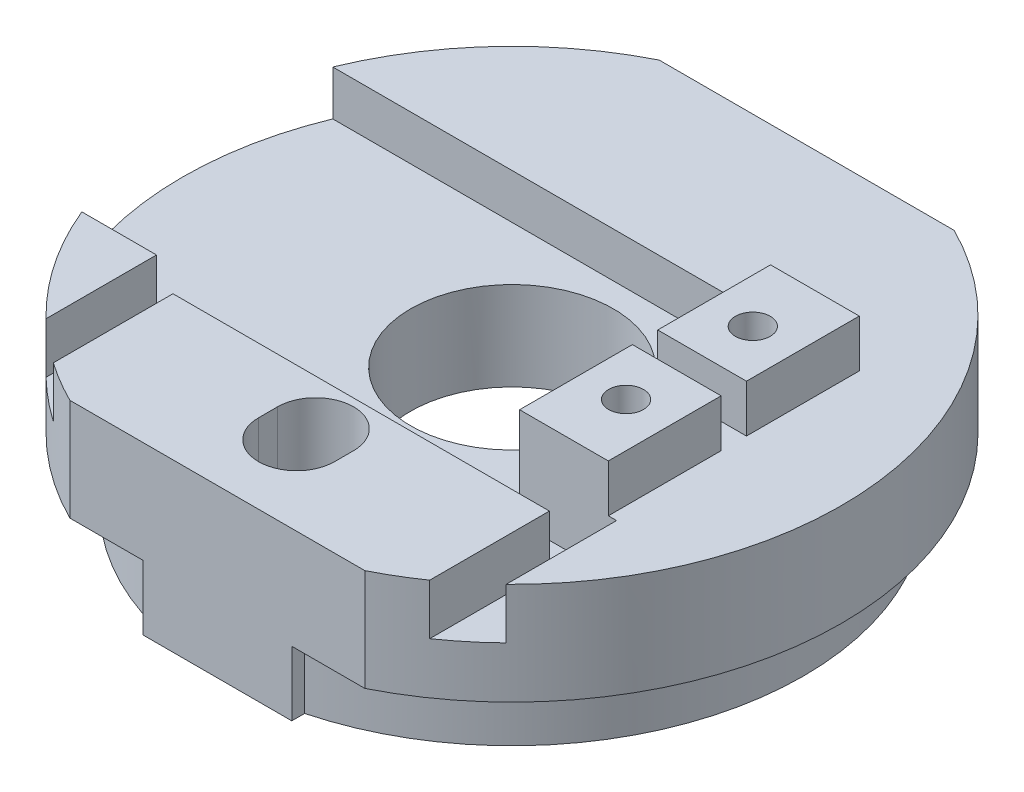
from build123d import *

# Parameters (mm, degrees)
SKETCH1_R           = 8
BOSS_EXTRUDE1_DEPTH = 10
SKETCH1_3_R         = 21.0025
BOSS_EXTRUDE2_DEPTH = 3.15
CUT_EXTRUDE1_DEPTH  = 4
SKETCH3_W           = 36.5
SKETCH3_H           = 19.8
CUT_EXTRUDE2_DEPTH  = 3
SKETCH4_W           = 7
SKETCH4_H           = 8.9
SKETCH4_R           = 1.375
BOSS_EXTRUDE3_DEPTH = 4.3
BOSS_EXTRUDE4_DEPTH = 3.15
CUT_EXTRUDE4_DEPTH  = 1.95
SKETCH9_R           = 21.0025
SKETCH9_R_2         = 8
BOSS_EXTRUDE8_DEPTH = 0.55
SKETCH10_R          = 8
CUT_EXTRUDE5_DEPTH  = 0.55
SKETCH11_W          = 7
SKETCH11_H          = 8.9
SKETCH11_R          = 1.375
CUT_EXTRUDE6_DEPTH  = 0.55


with BuildPart() as part:
    # Sketch1 → Boss-Extrude1 (new body)
    with BuildSketch(Plane(origin=(0, 0, 0), x_dir=(1, 0, 0), z_dir=(0, 1, 0))):
        with BuildLine():
            ThreePointArc((-11.637761812, 23.25), (-26, 0), (-11.637761812, -23.25))
            Line((-11.637761812, -23.25), (11.637761812, -23.25))
            ThreePointArc((11.637761812, -23.25), (26, 0), (11.637761812, 23.25))
            Line((11.637761812, 23.25), (-11.637761812, 23.25))
        make_face()
        Circle(SKETCH1_R, mode=Mode.SUBTRACT)
        with BuildLine():
            ThreePointArc((-3, -15.5), (0, -12.5), (3, -15.5))
            Line((3, -15.5), (3, -17))
            ThreePointArc((3, -17), (0, -20), (-3, -17))
            Line((-3, -17), (-3, -15.5))
        make_face(mode=Mode.SUBTRACT)
    extrude(amount=BOSS_EXTRUDE1_DEPTH)

    # Sketch1_3 → Boss-Extrude2 (add)
    with BuildSketch(Plane(origin=(0, 0, 0), x_dir=(1, 0, 0), z_dir=(0, 1, 0))):
        with BuildLine():
            Line((-5.874521255, -22.239716866), (-5.874521255, -23.25))
            Line((-5.874521255, -23.25), (5.874521255, -23.25))
            Line((5.874521255, -23.25), (5.874521255, -22.239716866))
            ThreePointArc((5.874521255, -22.239716866), (0, 23.0025), (-5.874521255, -22.239716866))
        make_face()
        Circle(SKETCH1_3_R, mode=Mode.SUBTRACT)
    extrude(amount=-BOSS_EXTRUDE2_DEPTH)

    # Sketch2 → Cut-Extrude1 (cut)
    with BuildSketch(Plane(origin=(0, 10, 0), x_dir=(1, 0, 0), z_dir=(0, 1, 0))):
        with BuildLine():
            Line((-18.15, -9.9), (-18.15, -18.616592062))
            ThreePointArc((-18.15, -18.616592062), (-16.556172611, -20.047272844), (-14.85, -21.341918845))
            Line((-14.85, -21.341918845), (-14.85, -11.9))
            Line((-14.85, -11.9), (14.85, -11.9))
            Line((14.85, -11.9), (14.85, -21.341918845))
            ThreePointArc((14.85, -21.341918845), (16.556172611, -20.047272844), (18.15, -18.616592062))
            Line((18.15, -18.616592062), (18.15, -9.9))
            Line((18.15, -9.9), (-18.15, -9.9))
        make_face()
    extrude(amount=-CUT_EXTRUDE1_DEPTH, mode=Mode.SUBTRACT)

    # Sketch3 → Cut-Extrude2 (cut)
    with BuildSketch(Plane(origin=(0, 10, 0), x_dir=(1, 0, 0), z_dir=(0, 1, 0))):
        with Locations((-7.75, 0)):
            Rectangle(SKETCH3_W, SKETCH3_H)
    extrude(amount=-CUT_EXTRUDE2_DEPTH, mode=Mode.SUBTRACT)

    # Sketch4 → Boss-Extrude3 (add)
    with BuildSketch(Plane(origin=(0, 10, 0), x_dir=(1, 0, 0), z_dir=(0, 1, 0))):
        with Locations((14, 5.45)):
            Rectangle(SKETCH4_W, SKETCH4_H)
        with Locations((14, 5)):
            Circle(SKETCH4_R, mode=Mode.SUBTRACT)
        with Locations((14, -5.45)):
            Rectangle(SKETCH4_W, SKETCH4_H)
        with Locations((14, -5)):
            Circle(SKETCH4_R, mode=Mode.SUBTRACT)
    extrude(amount=BOSS_EXTRUDE3_DEPTH)

    # Sketch6 → Boss-Extrude4 (add)
    with BuildSketch(Plane.XZ):
        with BuildLine():
            Line((-5.874521255, -23.25), (5.874521255, -23.25))
            Line((5.874521255, -23.25), (5.874521255, -22.239716866))
            ThreePointArc((5.874521255, -22.239716866), (0, -23.0025), (-5.874521255, -22.239716866))
            Line((-5.874521255, -22.239716866), (-5.874521255, -23.25))
        make_face()
    extrude(amount=BOSS_EXTRUDE4_DEPTH)

    # Sketch8 → Cut-Extrude4 (cut)
    with BuildSketch(Plane.XZ):
        with BuildLine():
            Line((-11.637761812, -23.25), (-5.874521255, -23.25))
            Line((-5.874521255, -23.25), (-5.874521255, -22.239716866))
            ThreePointArc((-5.874521255, -22.239716866), (-23.0025, 0), (-5.874521255, 22.239716866))
            Line((-5.874521255, 22.239716866), (-5.874521255, 23.25))
            Line((-5.874521255, 23.25), (-11.637761812, 23.25))
            ThreePointArc((-11.637761812, 23.25), (-26, 0), (-11.637761812, -23.25))
        make_face()
        with BuildLine():
            Line((5.874521255, 23.25), (5.874521255, 22.239716866))
            ThreePointArc((5.874521255, 22.239716866), (23.0025, 0), (5.874521255, -22.239716866))
            Line((5.874521255, -22.239716866), (5.874521255, -23.25))
            Line((5.874521255, -23.25), (11.637761812, -23.25))
            ThreePointArc((11.637761812, -23.25), (26, 0), (11.637761812, 23.25))
            Line((11.637761812, 23.25), (5.874521255, 23.25))
        make_face()
    extrude(amount=-CUT_EXTRUDE4_DEPTH, mode=Mode.SUBTRACT)

    # Sketch9 → Boss-Extrude8 (add)
    with BuildSketch(Plane.XZ):
        Circle(SKETCH9_R)
        Circle(SKETCH9_R_2, mode=Mode.SUBTRACT)
        with BuildLine():
            Line((-3, 15.5), (-3, 17))
            ThreePointArc((-3, 17), (0, 20), (3, 17))
            Line((3, 17), (3, 15.5))
            ThreePointArc((3, 15.5), (0, 12.5), (-3, 15.5))
        make_face(mode=Mode.SUBTRACT)
    extrude(amount=BOSS_EXTRUDE8_DEPTH)

    # Sketch10 → Cut-Extrude5 (cut)
    with BuildSketch(Plane(origin=(0, 7, 0), x_dir=(1, 0, 0), z_dir=(0, 1, 0))):
        with BuildLine():
            Line((-24.041422587, -9.9), (-18.15, -9.9))
            Line((-18.15, -9.9), (10.5, -9.9))
            Line((10.5, -9.9), (10.5, 9.9))
            Line((10.5, 9.9), (-24.041422587, 9.9))
            ThreePointArc((-24.041422587, 9.9), (-26, 0), (-24.041422587, -9.9))
        make_face()
        Circle(SKETCH10_R, mode=Mode.SUBTRACT)
    extrude(amount=-CUT_EXTRUDE5_DEPTH, mode=Mode.SUBTRACT)

    # Sketch11 → Cut-Extrude6 (cut)
    with BuildSketch(Plane(origin=(0, 14.3, 0), x_dir=(1, 0, 0), z_dir=(0, 1, 0))):
        with Locations((14, -5.45)):
            Rectangle(SKETCH11_W, SKETCH11_H)
        with Locations((14, -5)):
            Circle(SKETCH11_R, mode=Mode.SUBTRACT)
        with Locations((14, 5.45)):
            Rectangle(SKETCH11_W, SKETCH11_H)
        with Locations((14, 5)):
            Circle(SKETCH11_R, mode=Mode.SUBTRACT)
    extrude(amount=-CUT_EXTRUDE6_DEPTH, mode=Mode.SUBTRACT)


solid = part.part
